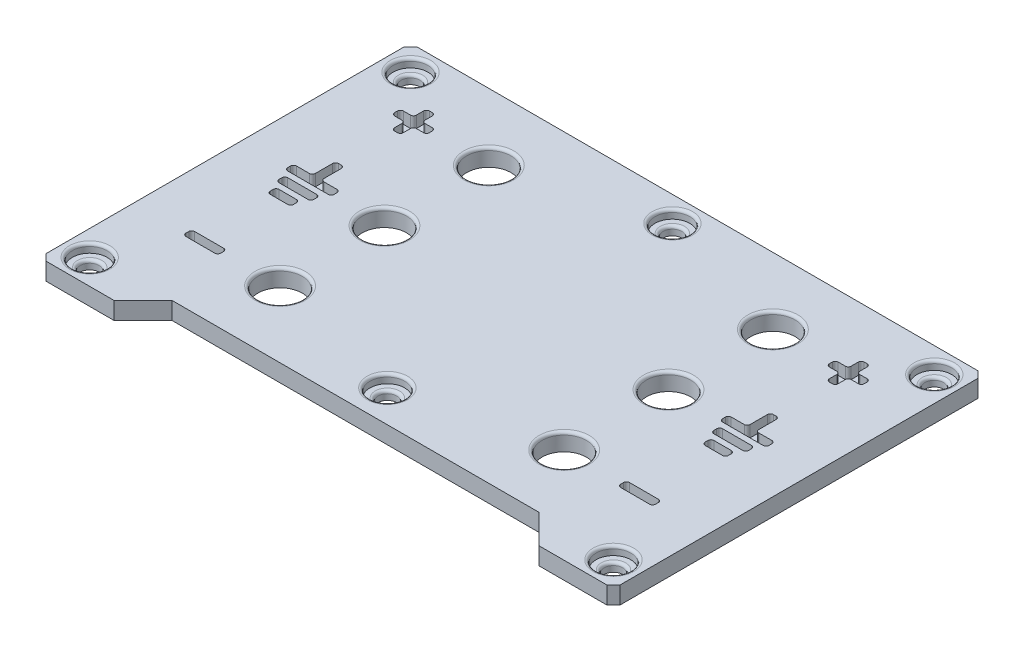
from build123d import *

# Parameters (mm, degrees)
SKETCH3_R           = 1.6
SKETCH3_R_2         = 3.825
BOSS_EXTRUDE1_DEPTH = 3
SKETCH4_R           = 3
CUT_EXTRUDE1_DEPTH  = 1.5
FILLET1_R           = 0.5
SKETCH5_W           = 6
SKETCH5_H           = 1.5
SKETCH5_W_2         = 4
CUT_EXTRUDE2_DEPTH  = 2
FILLET2_R           = 0.5


with BuildPart() as part:
    # Sketch3 → Boss-Extrude1 (new body)
    with BuildSketch(Plane(origin=(0, 0, 0), x_dir=(1, 0, 0), z_dir=(0, 1, 0))):
        Polygon((17.352282825, -19.043486229), (29.109642138, -19.043486229), (30.230962482, -17.922165885), (30.230962482, 43.835193428), (29.109642138, 44.956513771), (-67.647717175, 44.956513771), (-68.769037518, 43.835193428), (-68.769037518, -17.922165885), (-67.647717175, -19.043486229), (-55.890357862, -19.043486229), (-50.890357862, -14.043486229), (12.352282825, -14.043486229), align=None)
        with Locations((-64.439037518, 40.626513771)):
            Circle(SKETCH3_R, mode=Mode.SUBTRACT)
        with Locations((-64.439037518, -14.713486229)):
            Circle(SKETCH3_R, mode=Mode.SUBTRACT)
        with Locations((25.900962482, 40.626513771)):
            Circle(SKETCH3_R, mode=Mode.SUBTRACT)
        with Locations((25.900962482, -14.713486229)):
            Circle(SKETCH3_R, mode=Mode.SUBTRACT)
        with Locations((-43.769037518, 33.456513771)):
            Circle(SKETCH3_R_2, mode=Mode.SUBTRACT)
        with Locations((-43.769037518, 15.456513771)):
            Circle(SKETCH3_R_2, mode=Mode.SUBTRACT)
        with Locations((-43.769037518, -2.543486229)):
            Circle(SKETCH3_R_2, mode=Mode.SUBTRACT)
        with Locations((5.230962482, -2.543486229)):
            Circle(SKETCH3_R_2, mode=Mode.SUBTRACT)
        with Locations((5.230962482, 15.456513771)):
            Circle(SKETCH3_R_2, mode=Mode.SUBTRACT)
        with Locations((5.230962482, 33.456513771)):
            Circle(SKETCH3_R_2, mode=Mode.SUBTRACT)
        with Locations((-19.269037518, 40.626513771)):
            Circle(SKETCH3_R, mode=Mode.SUBTRACT)
        with Locations((-19.269037518, -8.543486229)):
            Circle(SKETCH3_R, mode=Mode.SUBTRACT)
    extrude(amount=-BOSS_EXTRUDE1_DEPTH)

    # Sketch4 → Cut-Extrude1 (cut)
    with BuildSketch(Plane(origin=(0, 0, 0), x_dir=(1, 0, 0), z_dir=(0, 1, 0))):
        with Locations((-64.439037518, 40.626513771)):
            Circle(SKETCH4_R)
        with Locations((-64.439037518, -14.713486229)):
            Circle(SKETCH4_R)
        with Locations((25.900962482, 40.626513771)):
            Circle(SKETCH4_R)
        with Locations((25.900962482, -14.713486229)):
            Circle(SKETCH4_R)
        with Locations((-19.269037518, 40.626513771)):
            Circle(SKETCH4_R)
        with Locations((-19.269037518, -8.543486229)):
            Circle(SKETCH4_R)
    extrude(amount=-CUT_EXTRUDE1_DEPTH, mode=Mode.SUBTRACT)

    # Fillet1
    fillet1_edges = [part.edges().sort_by_distance(p)[0] for p in [
        (-67.439037518, 0, 14.713486229),
        (-66.039037518, -1.5, 14.713486229),
        (-22.269037518, 0, 8.543486229),
        (-20.869037518, -1.5, 8.543486229),
        (-67.439037518, 0, -40.626513771),
        (-66.039037518, -1.5, -40.626513771),
        (-47.594037518, 0, -33.456513771),
        (-47.594037518, 0, -15.456513771),
        (-47.594037518, 0, 2.543486229),
        (1.405962482, 0, 2.543486229),
        (1.405962482, 0, -15.456513771),
        (1.405962482, 0, -33.456513771),
        (-22.269037518, 0, -40.626513771),
        (-20.869037518, -1.5, -40.626513771),
        (22.900962482, 0, 14.713486229),
        (24.300962482, -1.5, 14.713486229),
        (22.900962482, 0, -40.626513771),
        (24.300962482, -1.5, -40.626513771),
    ]]
    fillet(fillet1_edges, radius=FILLET1_R)

    # Sketch5 → Cut-Extrude2 (cut)
    with BuildSketch(Plane(origin=(0, 0, 0), x_dir=(1, 0, 0), z_dir=(0, 1, 0))):
        Polygon((-57.519037518, 30.456513771), (-56.019037518, 30.456513771), (-56.019037518, 32.706513771), (-53.769037518, 32.706513771), (-53.769037518, 34.206513771), (-56.019037518, 34.206513771), (-56.019037518, 36.456513771), (-57.519037518, 36.456513771), (-57.519037518, 34.206513771), (-59.769037518, 34.206513771), (-59.769037518, 32.706513771), (-57.519037518, 32.706513771), align=None)
        Polygon((-56.019037518, 16.770918537), (-52.769037518, 16.770918537), (-52.769037518, 15.270918537), (-60.769037518, 15.270918537), (-60.769037518, 16.770918537), (-57.519037518, 16.770918537), (-57.519037518, 20.770918537), (-56.019037518, 20.770918537), align=None)
        with Locations((-56.769037518, -2.543486229)):
            Rectangle(SKETCH5_W, SKETCH5_H)
        with Locations((-56.769037518, 13.520918537)):
            Rectangle(SKETCH5_W, SKETCH5_H)
        with Locations((-56.769037518, 11.020918537)):
            Rectangle(SKETCH5_W_2, SKETCH5_H)
    cut_extrude2 = extrude(amount=-CUT_EXTRUDE2_DEPTH, mode=Mode.SUBTRACT)

    # Mirror1: Cut-Extrude2 across plane
    add(cut_extrude2.mirror(Plane.ZY.offset(19.269037518)), mode=Mode.SUBTRACT)

    # Fillet2
    fillet2_edges = [part.edges().sort_by_distance(p)[0] for p in [
        (-56.019037518, -1, -36.456513771),
        (-56.019037518, -1, -34.206513771),
        (-53.769037518, -1, -34.206513771),
        (-53.769037518, -1, -32.706513771),
        (-56.019037518, -1, -32.706513771),
        (-56.019037518, -1, -30.456513771),
        (-57.519037518, -1, -30.456513771),
        (-57.519037518, -1, -32.706513771),
        (-59.769037518, -1, -32.706513771),
        (-59.769037518, -1, -34.206513771),
        (-57.519037518, -1, -34.206513771),
        (-57.519037518, -1, -36.456513771),
        (-53.769037518, -1, -14.270918537),
        (-53.769037518, -1, -12.770918537),
        (-59.769037518, -1, -12.770918537),
        (-59.769037518, -1, -14.270918537),
        (-54.769037518, -1, -11.770918537),
        (-54.769037518, -1, -10.270918537),
        (-58.769037518, -1, -10.270918537),
        (-58.769037518, -1, -11.770918537),
        (-56.019037518, -1, -20.770918537),
        (-56.019037518, -1, -16.770918537),
        (-52.769037518, -1, -16.770918537),
        (-52.769037518, -1, -15.270918537),
        (-60.769037518, -1, -15.270918537),
        (-60.769037518, -1, -16.770918537),
        (-57.519037518, -1, -16.770918537),
        (-57.519037518, -1, -20.770918537),
        (-53.769037518, -1, 1.793486229),
        (-53.769037518, -1, 3.293486229),
        (-59.769037518, -1, 3.293486229),
        (-59.769037518, -1, 1.793486229),
        (17.480962482, -1, -34.206513771),
        (17.480962482, -1, -36.456513771),
        (18.980962482, -1, -36.456513771),
        (18.980962482, -1, -34.206513771),
        (21.230962482, -1, -34.206513771),
        (21.230962482, -1, -32.706513771),
        (18.980962482, -1, -32.706513771),
        (18.980962482, -1, -30.456513771),
        (17.480962482, -1, -30.456513771),
        (17.480962482, -1, -32.706513771),
        (15.230962482, -1, -32.706513771),
        (15.230962482, -1, -34.206513771),
        (15.230962482, -1, -12.770918537),
        (15.230962482, -1, -14.270918537),
        (21.230962482, -1, -14.270918537),
        (21.230962482, -1, -12.770918537),
        (16.230962482, -1, -10.270918537),
        (16.230962482, -1, -11.770918537),
        (20.230962482, -1, -11.770918537),
        (20.230962482, -1, -10.270918537),
        (17.480962482, -1, -16.770918537),
        (17.480962482, -1, -20.770918537),
        (18.980962482, -1, -20.770918537),
        (18.980962482, -1, -16.770918537),
        (22.230962482, -1, -16.770918537),
        (22.230962482, -1, -15.270918537),
        (14.230962482, -1, -15.270918537),
        (14.230962482, -1, -16.770918537),
        (15.230962482, -1, 3.293486229),
        (15.230962482, -1, 1.793486229),
        (21.230962482, -1, 1.793486229),
        (21.230962482, -1, 3.293486229),
    ]]
    fillet(fillet2_edges, radius=FILLET2_R)


solid = part.part
